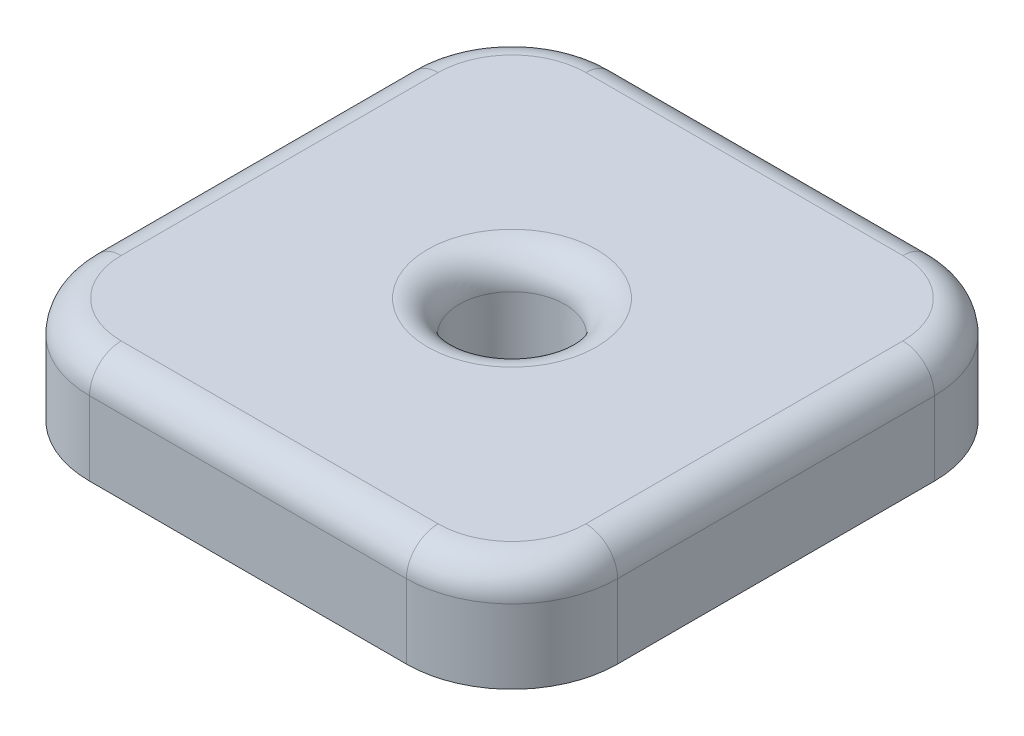
from build123d import *

# Parameters (mm, degrees)
SKETCH_1_W          = 50
SKETCH_1_H          = 50
EXTRUDE_1_DEPTH     = 10
FILLET_1_R          = 10
SKETCH_2_R          = 5
CUT_EXTRUDE_1_DEPTH = 10
FILLET_2_R          = 3


with BuildPart() as part:
    # 草图1 → 凸台-拉伸1 (new body)
    with BuildSketch(Plane(origin=(0, 0, 0), x_dir=(1, 0, 0), z_dir=(0, 1, 0))):
        Rectangle(SKETCH_1_W, SKETCH_1_H)
    extrude(amount=EXTRUDE_1_DEPTH)

    # 圆角1
    fillet_1_edges = [part.edges().sort_by_distance(p)[0] for p in [
        (25, 5, 25),
        (-25, 5, 25),
        (-25, 5, -25),
        (25, 5, -25),
    ]]
    fillet(fillet_1_edges, radius=FILLET_1_R)

    # 草图2 → 切除-拉伸1 (cut)
    with BuildSketch(Plane(origin=(0, 10, 0), x_dir=(1, 0, 0), z_dir=(0, 1, 0))):
        Circle(SKETCH_2_R)
    extrude(amount=-CUT_EXTRUDE_1_DEPTH, mode=Mode.SUBTRACT)

    # 圆角2
    fillet_2_edges = [part.edges().sort_by_distance(p)[0] for p in [
        (0, 10, 25),
        (-25, 10, 0),
        (25, 10, 0),
        (0, 10, -25),
        (22.071067812, 10, 22.071067812),
        (22.071067812, 10, -22.071067812),
        (-22.071067812, 10, -22.071067812),
        (-22.071067812, 10, 22.071067812),
        (-5, 10, 0),
    ]]
    fillet(fillet_2_edges, radius=FILLET_2_R)


solid = part.part
